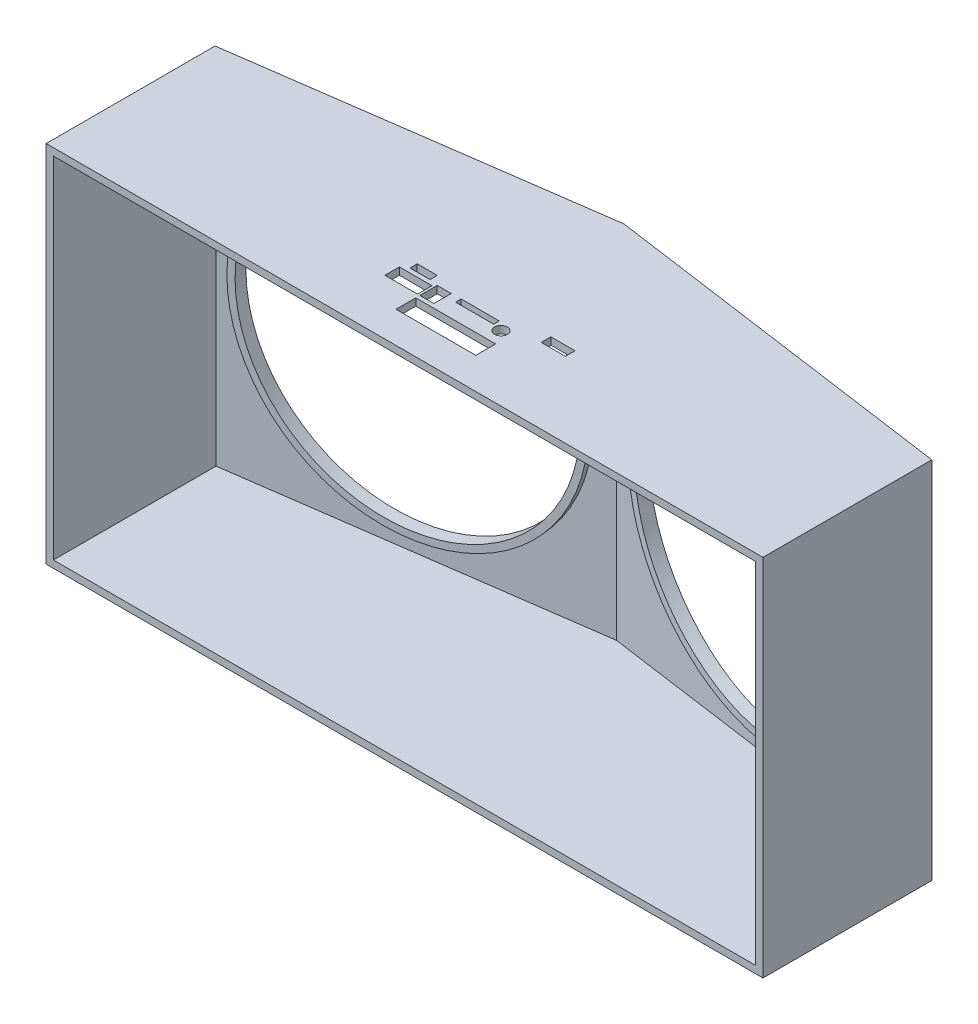
from build123d import *

# Parameters (mm, degrees)
SALIENTE_EXTRUIR1_DEPTH = 145
CROQUIS3_R              = 66.25
CROQUIS3_R_2            = 63.25
SALIENTE_EXTRUIR2_DEPTH = 2.3
CROQUIS5_R              = 66.25
CROQUIS5_R_2            = 63.25
SALIENTE_EXTRUIR3_DEPTH = 2.3
CROQUIS6_R              = 63.25
CORTAR_EXTRUIR3_DEPTH   = 24.61469423
CROQUIS7_R              = 63.25
CORTAR_EXTRUIR4_DEPTH   = 24.61469423
SALIENTE_EXTRUIR4_DEPTH = 3
CROQUIS10_W             = 3
CROQUIS10_H             = 70
SALIENTE_EXTRUIR5_DEPTH = 148
SALIENTE_EXTRUIR6_DEPTH = 3
CROQUIS12_R             = 2.65
CROQUIS12_W             = 33.1
CROQUIS12_H             = 8.2
CROQUIS12_W_2           = 5.8
CROQUIS12_H_2           = 7.2
CROQUIS12_W_3           = 15.8
CROQUIS12_H_3           = 2.3
CROQUIS12_W_4           = 13.5
CROQUIS12_H_4           = 6
CROQUIS12_W_5           = 8.3
CROQUIS12_H_5           = 3
CROQUIS12_W_6           = 10
CROQUIS12_H_6           = 4
CORTAR_EXTRUIR5_DEPTH   = 10


with BuildPart() as part:
    # Croquis2 → Saliente-Extruir1 (new body)
    with BuildSketch(Plane(origin=(0, 0, 0), x_dir=(1, 0, 0), z_dir=(0, 1, 0))):
        Polygon((0, 90.302866191), (148.540210311, 69.426901047), (148.540210311, 72.456383764), (0.417519303, 93.273670397), (-0.417519303, 93.273670397), (-148.540210311, 72.456383764), (-148.540210311, 69.426901047), align=None)
    extrude(amount=SALIENTE_EXTRUIR1_DEPTH)

    # Croquis3 → Saliente-Extruir2 (add)
    with BuildSketch(Plane(origin=(12.44542163, 0, -88.553776247), x_dir=(0.990268069, 0, 0.139173101), z_dir=(-0.139173101, 0, 0.990268069))):
        with Locations((62.432270087, 72.5)):
            Circle(CROQUIS3_R)
        with Locations((62.432270087, 72.5)):
            Circle(CROQUIS3_R_2, mode=Mode.SUBTRACT)
    extrude(amount=SALIENTE_EXTRUIR2_DEPTH)

    # Croquis5 → Saliente-Extruir3 (add)
    with BuildSketch(Plane(origin=(-12.44542163, 0, -88.553776247), x_dir=(0.990268069, 0, -0.139173101), z_dir=(0.139173101, 0, 0.990268069))):
        with Locations((-62.432270087, 72.5)):
            Circle(CROQUIS5_R)
        with Locations((-62.432270087, 72.5)):
            Circle(CROQUIS5_R_2, mode=Mode.SUBTRACT)
    extrude(amount=SALIENTE_EXTRUIR3_DEPTH)

    # Croquis6 → Cortar-Extruir3 (cut, through all)
    with BuildSketch(Plane(origin=(-12.44542163, 0, -88.553776247), x_dir=(0.990268069, 0, -0.139173101), z_dir=(0.139173101, 0, 0.990268069))):
        with Locations((-62.432270087, 72.5)):
            Circle(CROQUIS6_R)
    extrude(amount=-CORTAR_EXTRUIR3_DEPTH, mode=Mode.SUBTRACT)

    # Croquis7 → Cortar-Extruir4 (cut, through all)
    with BuildSketch(Plane(origin=(12.44542163, 0, -88.553776247), x_dir=(0.990268069, 0, 0.139173101), z_dir=(-0.139173101, 0, 0.990268069))):
        with Locations((62.432270087, 72.5)):
            Circle(CROQUIS7_R)
    extrude(amount=-CORTAR_EXTRUIR4_DEPTH, mode=Mode.SUBTRACT)

    # Croquis9 → Saliente-Extruir4 (add)
    with BuildSketch(Plane.XZ):
        Polygon((-148.540210311, -72.456383764), (-0.417519303, -93.273670397), (0.417519303, -93.273670397), (148.540210311, -72.456383764), (148.540210311, -2.456383764), (-148.540210311, -2.456383764), align=None)
    extrude(amount=SALIENTE_EXTRUIR4_DEPTH)

    # Croquis10 → Saliente-Extruir5 (add)
    with BuildSketch(Plane.XZ.offset(3)):
        with Locations((-147.040210311, -37.456383764)):
            Rectangle(CROQUIS10_W, CROQUIS10_H)
        with Locations((147.040210311, -37.456383764)):
            Rectangle(CROQUIS10_W, CROQUIS10_H)
    extrude(amount=-SALIENTE_EXTRUIR5_DEPTH)

    # Croquis11 → Saliente-Extruir6 (add)
    with BuildSketch(Plane(origin=(0, 145, 0), x_dir=(1, 0, 0), z_dir=(0, 1, 0))):
        Polygon((148.540210311, 72.456383764), (0.417519303, 93.273670397), (-0.417519303, 93.273670397), (-148.540210311, 72.456383764), (-148.540210311, 2.456383764), (148.540210311, 2.456383764), align=None)
    extrude(amount=SALIENTE_EXTRUIR6_DEPTH)

    # Croquis12 → Cortar-Extruir5 (cut)
    with BuildSketch(Plane.XZ.offset(-145)):
        with Locations((12.9, -29.517649177)):
            Circle(CROQUIS12_R)
        with Locations((0, -19.556383764)):
            Rectangle(CROQUIS12_W, CROQUIS12_H)
        with Locations((-13.65, -28.956383764)):
            Rectangle(CROQUIS12_W_2, CROQUIS12_H_2)
        with Locations((1.15, -31.506383764)):
            Rectangle(CROQUIS12_W_3, CROQUIS12_H_3)
        with Locations((-24.3, -28.356383764)):
            Rectangle(CROQUIS12_W_4, CROQUIS12_H_4)
        with Locations((-24.3, -34.656383764)):
            Rectangle(CROQUIS12_W_5, CROQUIS12_H_5)
        with Locations((30.45, -35.656383764)):
            Rectangle(CROQUIS12_W_6, CROQUIS12_H_6)
    extrude(amount=-CORTAR_EXTRUIR5_DEPTH, mode=Mode.SUBTRACT)


solid = part.part
